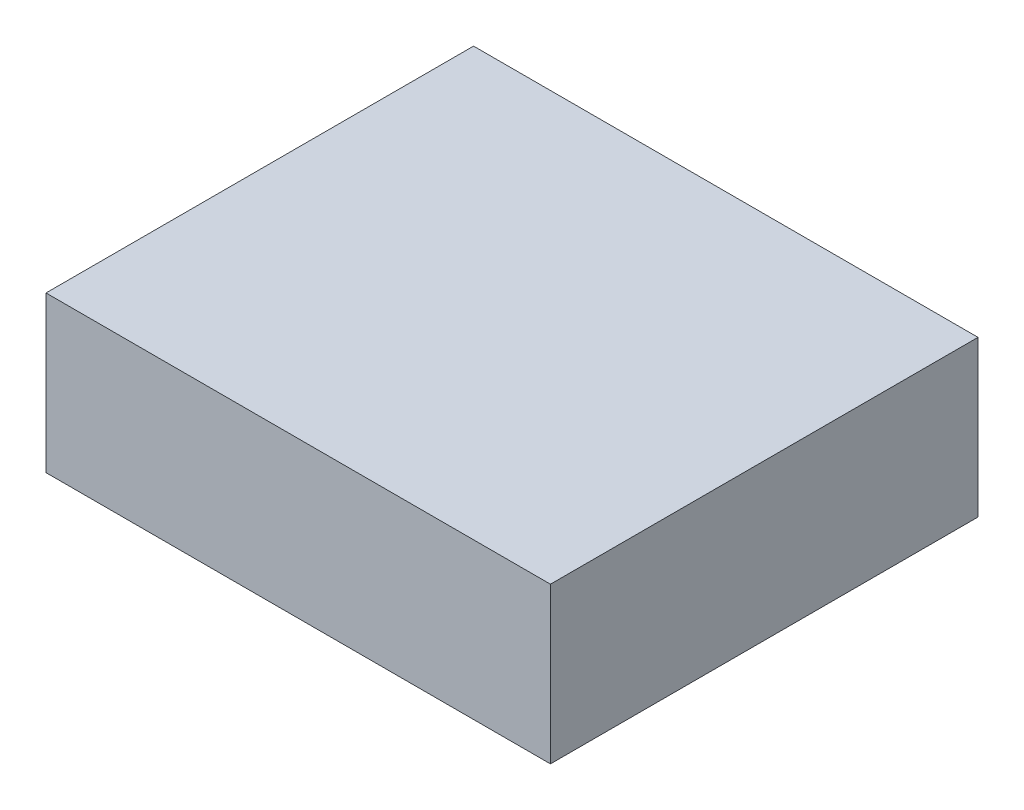
from build123d import *

# Parameters (mm, degrees)
SKETCH1_W           = 68.326
SKETCH1_H           = 57.912
BOSS_EXTRUDE1_DEPTH = 21.082


with BuildPart() as part:
    # Sketch1 → Boss-Extrude1 (new body)
    with BuildSketch(Plane(origin=(0, 0, 0), x_dir=(1, 0, 0), z_dir=(0, 1, 0))):
        Rectangle(SKETCH1_W, SKETCH1_H)
    extrude(amount=BOSS_EXTRUDE1_DEPTH)


solid = part.part
